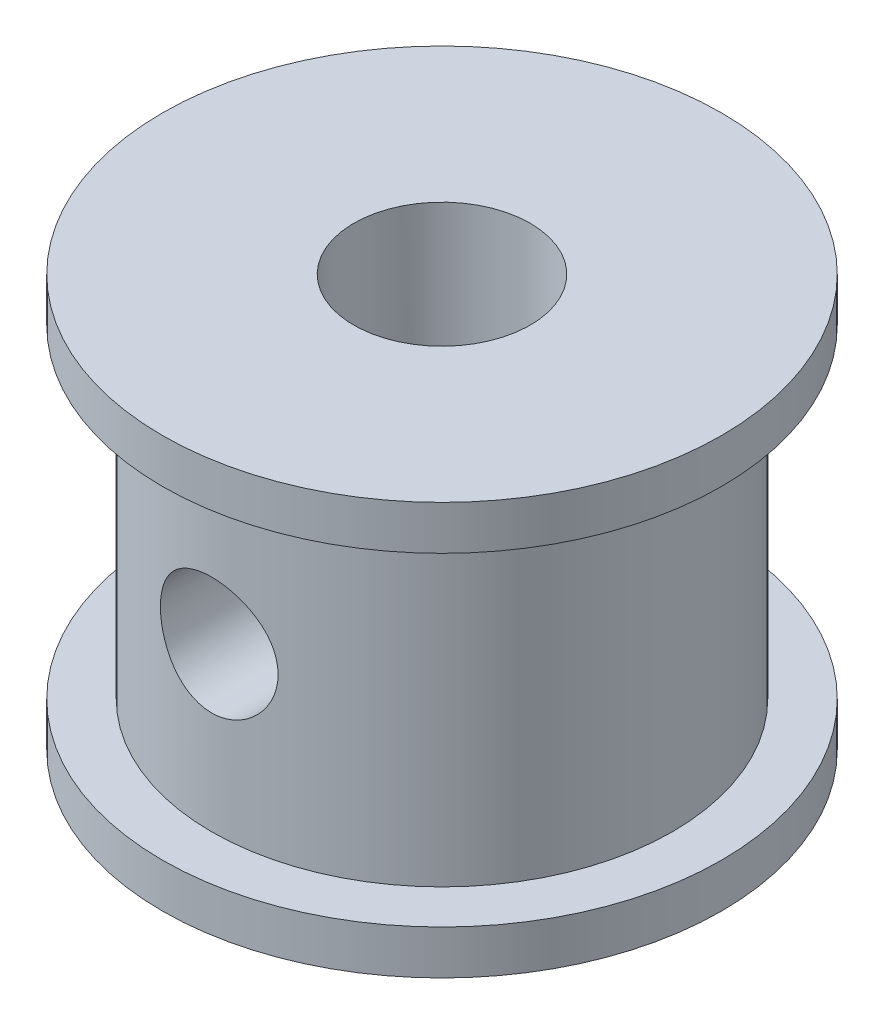
from build123d import *

# Parameters (mm, degrees)
EXTRUDE_1_DEPTH      = 5.5
EXTRUDE_1_DEPTH_BACK = 5.5
SKETCH_1_R           = 7.83
SKETCH_3_R           = 9.5
EXTRUDE_3_DEPTH      = 1.5
EXTRUDE_START        = 1.5
SKETCH_4_R           = 9.5
EXTRUDE_4_DEPTH      = 1.5
SKETCH_5_R           = 3
CUT_EXTRUDE_1_DEPTH  = 20.403607912
SKETCH_6_R           = 2
CUT_EXTRUDE_2_DEPTH  = 16.149257408
SKETCH_7_R           = 2
CUT_EXTRUDE_3_DEPTH  = 16.149257454


with BuildPart() as part:
    # 草圖1 → 填料-伸長1 (new, two sides: drawn at the far end of the back side and taken through both)
    with BuildSketch(Plane(origin=(0, 0, 0), x_dir=(1, 0, 0), z_dir=(0, 1, 0)).offset(-EXTRUDE_1_DEPTH_BACK)):
        Circle(SKETCH_1_R)
    extrude(amount=EXTRUDE_1_DEPTH + EXTRUDE_1_DEPTH_BACK)

    # 草圖3 → 填料-伸長3 (add)
    with BuildSketch(Plane.XZ.offset(5.5)):
        Circle(SKETCH_3_R)
    extrude(amount=EXTRUDE_3_DEPTH)

    # 草圖4 → 填料-伸長4 (add)
    with BuildSketch(Plane(origin=(0, 5.5, 0), x_dir=(1, 0, 0), z_dir=(0, 1, 0)).offset(EXTRUDE_START)):
        Circle(SKETCH_4_R)
    extrude(amount=-EXTRUDE_4_DEPTH)

    # 草圖5 → 除料-伸長1 (cut, through all)
    with BuildSketch(Plane.XZ.offset(7)):
        Circle(SKETCH_5_R)
    extrude(amount=-CUT_EXTRUDE_1_DEPTH, mode=Mode.SUBTRACT)

    # 草圖6 → 除料-伸長2 (cut, through all)
    with BuildSketch(Plane.XY):
        Circle(SKETCH_6_R)
    extrude(amount=CUT_EXTRUDE_2_DEPTH, mode=Mode.SUBTRACT)

    # 草圖7 → 除料-伸長3 (cut, through all)
    with BuildSketch(Plane(origin=(0, 0, 0), x_dir=(0, 0, -1), z_dir=(1, 0, 0))):
        Circle(SKETCH_7_R)
    extrude(amount=-CUT_EXTRUDE_3_DEPTH, mode=Mode.SUBTRACT)


solid = part.part
